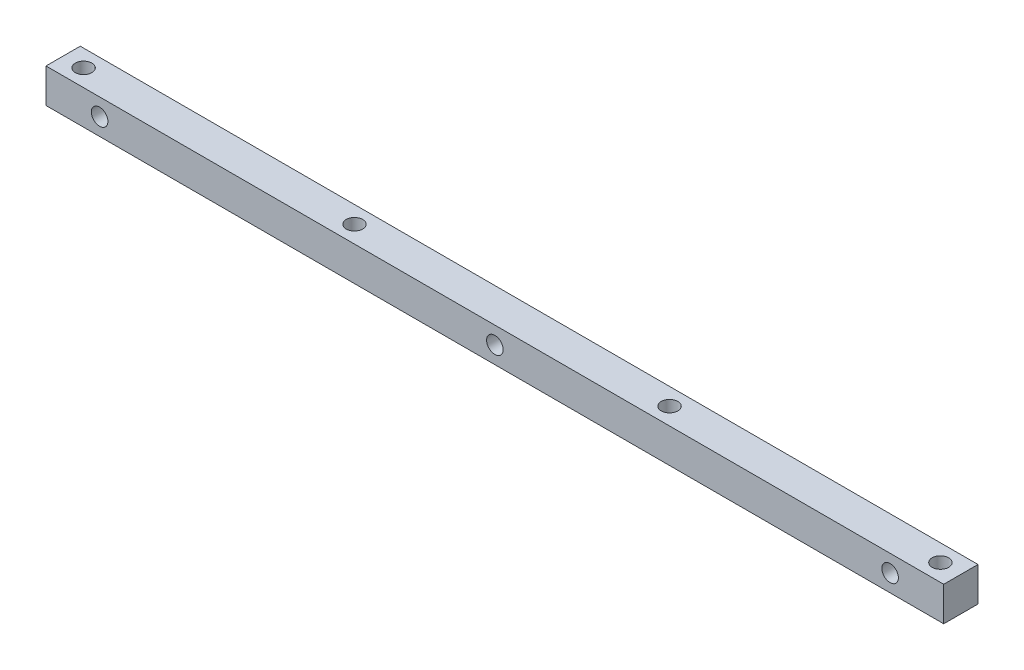
from build123d import *

# Parameters (mm, degrees)
CROQUIS1_W              = 162.4
CROQUIS1_H              = 6.2
CROQUIS1_R              = 1.5
SALIENTE_EXTRUIR1_DEPTH = 6.2
CROQUIS2_R              = 1.5
CORTAR_EXTRUIR1_DEPTH   = 6.2


with BuildPart() as part:
    # Croquis1 → Saliente-Extruir1 (new body)
    with BuildSketch(Plane.XY):
        Rectangle(CROQUIS1_W, CROQUIS1_H)
        with Locations((-71.5, 0)):
            Circle(CROQUIS1_R, mode=Mode.SUBTRACT)
        Circle(CROQUIS1_R, mode=Mode.SUBTRACT)
        with Locations((71.5, 0)):
            Circle(CROQUIS1_R, mode=Mode.SUBTRACT)
    extrude(amount=SALIENTE_EXTRUIR1_DEPTH)

    # Croquis2 → Cortar-Extruir1 (cut)
    with BuildSketch(Plane(origin=(0, 3.1, 0), x_dir=(1, 0, 0), z_dir=(0, 1, 0))):
        with Locations((-77.5, -3.1)):
            Circle(CROQUIS2_R)
        with Locations((-28.5, -3.1)):
            Circle(CROQUIS2_R)
        with Locations((28.5, -3.1)):
            Circle(CROQUIS2_R)
        with Locations((77.5, -3.1)):
            Circle(CROQUIS2_R)
    extrude(amount=-CORTAR_EXTRUIR1_DEPTH, mode=Mode.SUBTRACT)


solid = part.part
